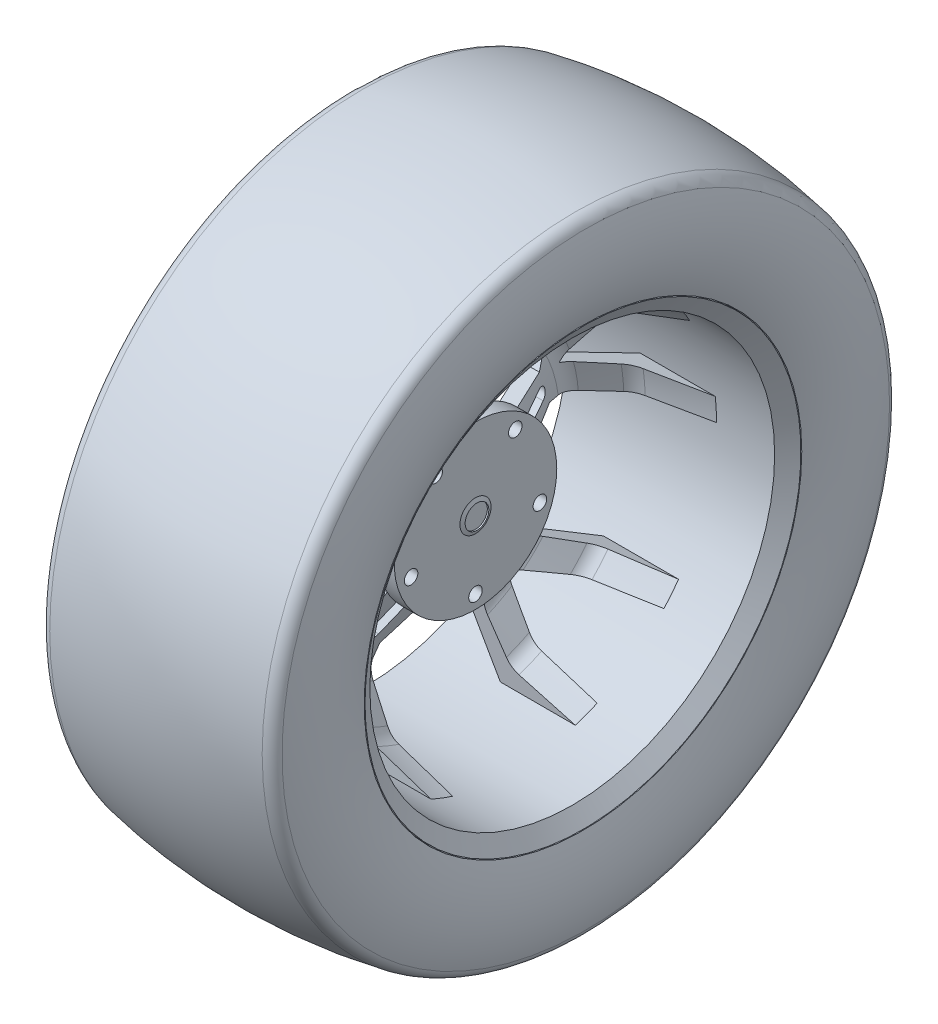
from build123d import *

# Parameters (mm, degrees)
CUT_EXTRUDE1_DEPTH  = 360.68
CIRPATTERN1_COUNT   = 5
CUT_EXTRUDE2_DEPTH  = 158.75
CIRPATTERN2_COUNT   = 5
BOSS_EXTRUDE1_START = 76.2
SKETCH4_R           = 60
BOSS_EXTRUDE1_DEPTH = 12.7
SKETCH5_R           = 5
CUT_EXTRUDE3_DEPTH  = 66.802
CIRPATTERN3_COUNT   = 5


with BuildPart() as part:
    # Sketch1 → Revolve2 (revolve)
    with BuildSketch(Plane(origin=(0, 0, 0), x_dir=(1, 0, 0), z_dir=(0, 1, 0)), mode=Mode.PRIVATE) as revolve2_sk:
        with BuildLine():
            Line((-84.122331, 160.883907), (-76.2, 149.400685))
            Line((-76.2, 149.400685), (-22.154592, 149.400685))
            Line((-22.154592, 149.400685), (-41.065973, 109.082648))
            ThreePointArc((-41.065973, 109.082648), (-42.502924, 103.019221), (-41.392892, 96.887517))
            Line((-41.392892, 96.887517), (-5.675794, 8.741652))
            Line((-5.675794, 8.741652), (5.894426, 8.741652))
            Line((5.894426, 8.741652), (-29.50433, 96.101885))
            ThreePointArc((-29.50433, 96.101885), (-30.57975, 102.929832), (-28.528416, 109.530544))
            Line((-28.528416, 109.530544), (-16.261285, 130.463448))
            ThreePointArc((-16.261285, 130.463448), (-12.506059, 134.759034), (-7.434237, 137.37254))
            Line((-7.434237, 137.37254), (33.242218, 149.400685))
            Line((33.242218, 149.400685), (76.2, 149.400685))
            Line((76.2, 149.400685), (84.122331, 160.883907))
            Line((84.122331, 160.883907), (76.2, 160.883907))
            Line((76.2, 160.883907), (72.064641, 154.889807))
            Line((72.064641, 154.889807), (-72.064641, 154.889807))
            Line((-72.064641, 154.889807), (-76.2, 160.883907))
            Line((-76.2, 160.883907), (-84.122331, 160.883907))
        make_face()
    revolve(revolve2_sk.sketch.rotate(Axis((-50.391488, 0, 0), (1, 0, 0)), 180), axis=Axis((-50.391488, 0, 0), (1, 0, 0)))

    # Sketch2 → Cut-Extrude1 (cut)
    with BuildSketch(Plane(origin=(-84.122331, 0, 0), x_dir=(0, 0, -1), z_dir=(1, 0, 0))):
        with BuildLine():
            Line((30.44831, 146.265051), (0, 102.180479))
            Line((0, 102.180479), (-30.44831, 146.265051))
            ThreePointArc((-30.44831, 146.265051), (0, 149.400685), (30.44831, 146.265051))
        make_face()
        with BuildLine():
            Line((47.031653, 141.804754), (12.145468, 85.346309))
            Line((12.145468, 85.346309), (19.278129, 39.4819))
            ThreePointArc((19.278129, 39.4819), (21.921499, 38.077744), (24.463134, 36.496873))
            Line((24.463134, 36.496873), (47.031653, 141.804754))
        make_face()
        with BuildLine():
            Line((-24.463134, 36.496873), (-47.031653, 141.804754))
            Line((-47.031653, 141.804754), (-12.145468, 85.346309))
            Line((-12.145468, 85.346309), (-19.278129, 39.4819))
            ThreePointArc((-19.278129, 39.4819), (-21.921499, 38.077744), (-24.463134, 36.496873))
        make_face()
        with BuildLine():
            Line((-4.593691, 29.396708), (-4.593691, 80.438899))
            ThreePointArc((-4.593691, 80.438899), (0, 85.03259), (4.593691, 80.438899))
            Line((4.593691, 80.438899), (4.593691, 29.396708))
            ThreePointArc((4.593691, 29.396708), (0, 24.803017), (-4.593691, 29.396708))
        make_face()
    cut_extrude1 = extrude(amount=CUT_EXTRUDE1_DEPTH, mode=Mode.SUBTRACT)

    # CirPattern1: Cut-Extrude1 ×5 about axis
    cirpattern1_axis = Axis((0, 0, 0), (1, 0, 0))
    for i in range(1, CIRPATTERN1_COUNT):
        add(cut_extrude1.rotate(cirpattern1_axis, i * 360 / CIRPATTERN1_COUNT), mode=Mode.SUBTRACT)

    # Sketch3 → Cut-Extrude2 (cut)
    with BuildSketch(Plane(origin=(-84.122331, 0, 0), x_dir=(0, 0, -1), z_dir=(1, 0, 0))):
        with BuildLine():
            Line((47.031653, 141.804754), (24.463134, 36.496873))
            ThreePointArc((24.463134, 36.496873), (25.825566, 35.545842), (27.151065, 34.543977))
            Line((27.151065, 34.543977), (120.330756, 88.549839))
            ThreePointArc((120.330756, 88.549839), (87.81552, 120.867693), (47.031653, 141.804754))
        make_face()
    cut_extrude2 = extrude(amount=CUT_EXTRUDE2_DEPTH, mode=Mode.SUBTRACT)

    # CirPattern2: Cut-Extrude2 ×5 about axis
    cirpattern2_axis = Axis((72.064641, 0, 0), (-1, 0, 0))
    for i in range(1, CIRPATTERN2_COUNT):
        add(cut_extrude2.rotate(cirpattern2_axis, i * 360 / CIRPATTERN2_COUNT), mode=Mode.SUBTRACT)

    # Sketch4 → Boss-Extrude1 (add)
    with BuildSketch(Plane(origin=(-84.122331, 0, 0), x_dir=(0, 0, -1), z_dir=(1, 0, 0)).offset(BOSS_EXTRUDE1_START)):
        Circle(SKETCH4_R)
    extrude(amount=BOSS_EXTRUDE1_DEPTH)

    # Sketch5 → Cut-Extrude3 (cut)
    with BuildSketch(Plane(origin=(4.777669, 0, 0), x_dir=(0, 0, -1), z_dir=(1, 0, 0))):
        with Locations((0, -50)):
            Circle(SKETCH5_R)
    cut_extrude3 = extrude(amount=-CUT_EXTRUDE3_DEPTH, mode=Mode.SUBTRACT)

    # CirPattern3: Cut-Extrude3 ×5 about axis
    cirpattern3_axis = Axis((0, 0, 0), (1, 0, 0))
    for i in range(1, CIRPATTERN3_COUNT):
        add(cut_extrude3.rotate(cirpattern3_axis, i * 360 / CIRPATTERN3_COUNT), mode=Mode.SUBTRACT)


with BuildPart() as body_2:
    # Sketch6 → Revolve3 (revolve)
    with BuildSketch(Plane(origin=(0, 0, 0), x_dir=(1, 0, 0), z_dir=(0, 1, 0))):
        with BuildLine():
            Line((-84.122331, 161.492488), (-76.525912, 161.46501))
            Line((-76.525912, 161.46501), (-72.064641, 154.889807))
            Line((-72.064641, 154.889807), (-63.657206, 160.594247))
            Line((-63.657206, 160.594247), (-71.12837, 171.605552))
            Line((-71.12837, 171.605552), (-76.922718, 171.626512))
            ThreePointArc((-76.922718, 171.626512), (-80.520564, 196.372769), (-76.525912, 221.058079))
            ThreePointArc((-76.525912, 221.058079), (0, 228.165782), (76.525912, 221.058079))
            ThreePointArc((76.525912, 221.058079), (80.520454, 196.38635), (76.930657, 171.652488))
            Line((76.930657, 171.652488), (70.757962, 171.652488))
            Line((70.757962, 171.652488), (63.041961, 161.297079))
            Line((63.041961, 161.297079), (71.189013, 155.226564))
            Line((71.189013, 155.226564), (75.857865, 161.492488))
            Line((75.857865, 161.492488), (84.122331, 161.492488))
            ThreePointArc((84.122331, 161.492488), (90.632804, 192.657878), (86.192788, 224.184916))
            ThreePointArc((86.192788, 224.184916), (83.237424, 228.68574), (78.397086, 231.044285))
            ThreePointArc((78.397086, 231.044285), (0, 238.325782), (-78.397086, 231.044285))
            ThreePointArc((-78.397086, 231.044285), (-83.237424, 228.68574), (-86.192788, 224.184916))
            ThreePointArc((-86.192788, 224.184916), (-90.632804, 192.657878), (-84.122331, 161.492488))
        make_face()
    revolve(axis=Axis((72.064641, 0, 0), (-1, 0, 0)))


solid = Compound([part.part, body_2.part])
